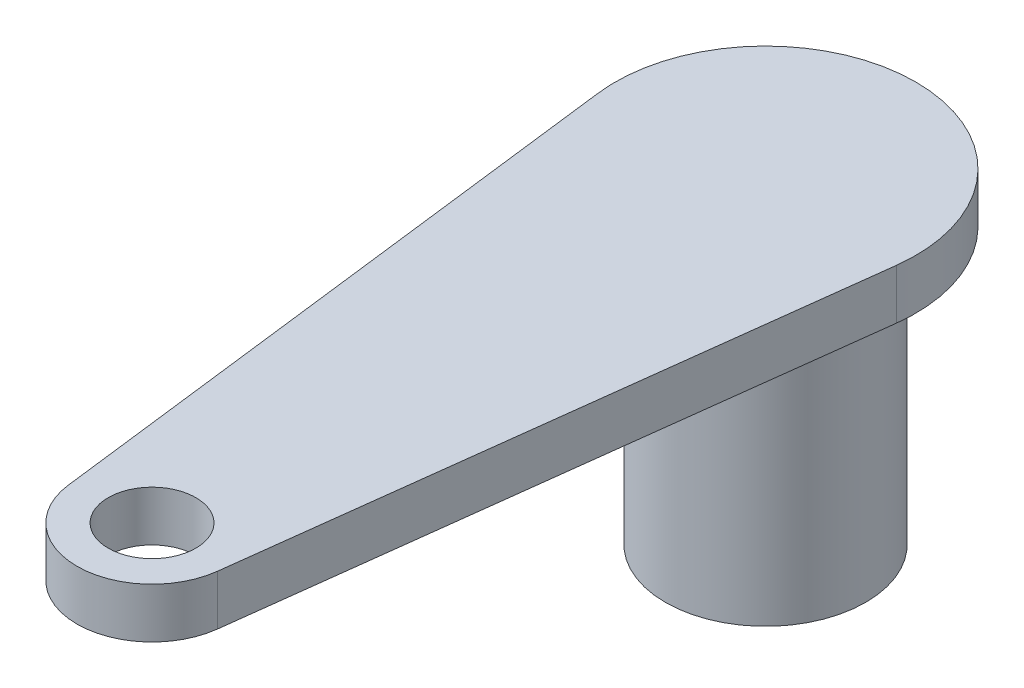
from build123d import *

# Parameters (mm, degrees)
SKETCH1_R           = 4
SKETCH1_R_2         = 3
BOSS_EXTRUDE1_DEPTH = 11
SKETCH2_R           = 27.5
SKETCH2_R_2         = 1.75
BOSS_EXTRUDE2_DEPTH = 2
SKETCH3_R           = 41.685165186
SKETCH3_R_2         = 27.5
CUT_EXTRUDE2_DEPTH  = 42.006097108


with BuildPart() as part:
    # Sketch1 → Boss-Extrude1 (new body)
    with BuildSketch(Plane(origin=(0, 0, 0), x_dir=(1, 0, 0), z_dir=(0, 1, 0))):
        with Locations(Location((0, 0, 0), (0, 0, 270))):
            Circle(SKETCH1_R)
        with Locations(Location((0, 0, 0), (0, 0, 270))):
            Circle(SKETCH1_R_2, mode=Mode.SUBTRACT)
    extrude(amount=BOSS_EXTRUDE1_DEPTH)


with BuildPart() as body_2:
    # Sketch2 → Boss-Extrude2 (new body)
    with BuildSketch(Plane(origin=(0, 11, 0), x_dir=(1, 0, 0), z_dir=(0, 1, 0))):
        with Locations(Location((0, 0, 0), (0, 0, 270))):
            Circle(SKETCH2_R)
        with Locations(Location((0, -24.5, 0), (0, 0, 270))):
            Circle(SKETCH2_R_2, mode=Mode.SUBTRACT)
    extrude(amount=BOSS_EXTRUDE2_DEPTH)

    # Sketch3 → Cut-Extrude2 (cut, through all)
    with BuildSketch(Plane(origin=(0, 13, 0), x_dir=(1, 0, 0), z_dir=(0, 1, 0))):
        Circle(SKETCH3_R)
        Circle(SKETCH3_R_2, mode=Mode.SUBTRACT)
        with BuildLine():
            ThreePointArc((27.5, 0), (-19.445436483, 19.445436483), (0, -27.5))
            ThreePointArc((0, -27.5), (19.445436483, -19.445436483), (27.5, 0))
        make_face()
        with BuildLine():
            ThreePointArc((0, -27.5), (-1.987203963, -26.747447532), (-2.977424428, -24.867346939))
            Line((-2.977424428, -24.867346939), (-5.954848857, -0.734693878))
            ThreePointArc((-5.954848857, -0.734693878), (-0.368039984, 5.988701576), (6, 0))
            ThreePointArc((6, 0), (5.988701576, -0.368039984), (5.954848857, -0.734693878))
            Line((5.954848857, -0.734693878), (2.977424428, -24.867346939))
            ThreePointArc((2.977424428, -24.867346939), (1.987203963, -26.747447532), (0, -27.5))
        make_face(mode=Mode.SUBTRACT)
    extrude(amount=-CUT_EXTRUDE2_DEPTH, mode=Mode.SUBTRACT)


solid = Compound([part.part, body_2.part])
